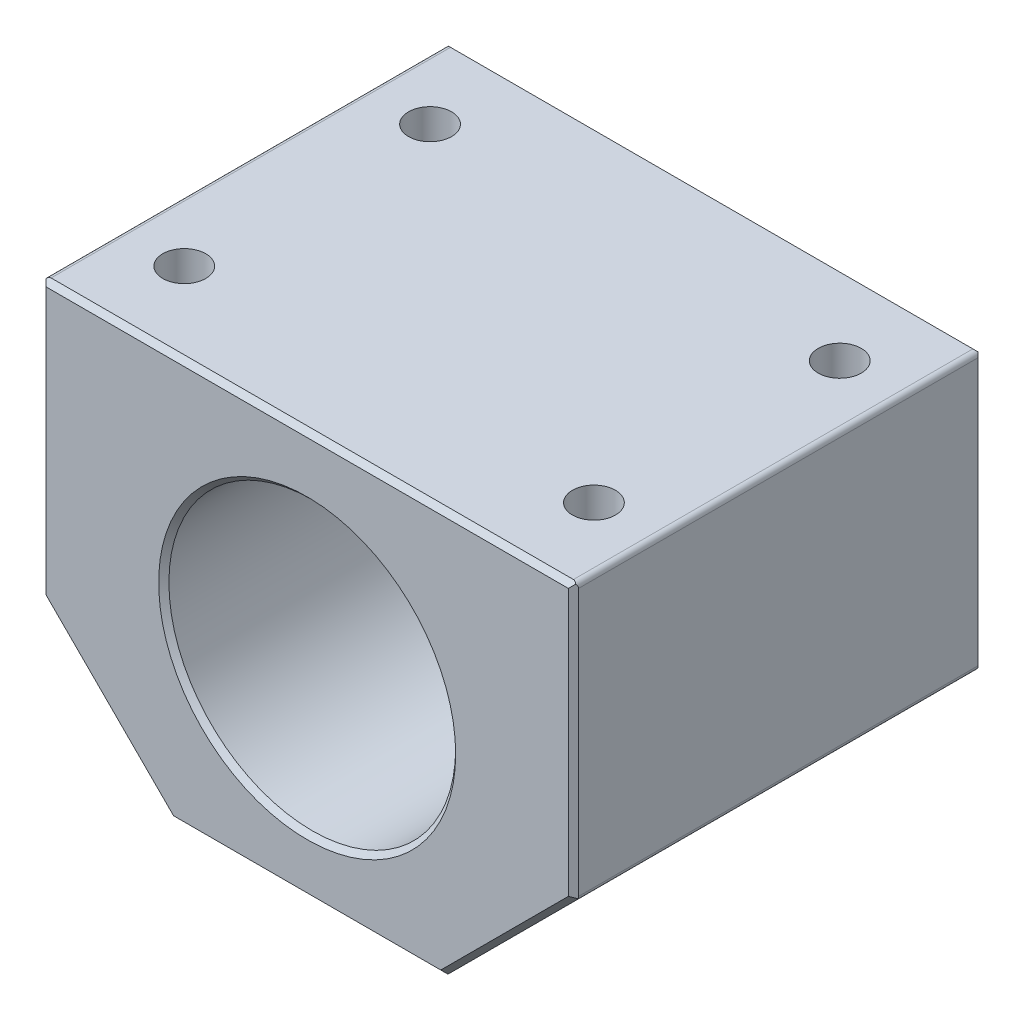
from build123d import *

# Parameters (mm, degrees)
SKETCH1_R                      = 14
BOSS_EXTRUDE1_DEPTH            = 20
CIRPATTERN1_COUNT              = 3
CIRPATTERN1_ANGLE              = 90
M5X0_8_TAPPED_HOLE2_AT_2_COUNT = 2
M5X0_8_TAPPED_HOLE2_AT_2_PITCH = 24
CHAMFER1_SIZE                  = 0.5
FILLET1_R                      = 0.5


with BuildPart() as part:
    # Sketch1 → Boss-Extrude1 (new body, symmetric)
    with BuildSketch(Plane.XY):
        Polygon((-13.25, -19.5), (13.25, -19.5), (26, -6.75), (26, 20), (-26, 20), (-26, -6.75), align=None)
        Circle(SKETCH1_R, mode=Mode.SUBTRACT)
    extrude(amount=BOSS_EXTRUDE1_DEPTH, both=True)

    # Sketch4 → M5x0.8 Tapped Hole1 (revolve, cut)
    with BuildSketch(Plane(origin=(13.435028843, 13.435028843, -20), x_dir=(0, 1, 0), z_dir=(1, 0, 0))):
        Polygon((0, 0), (0, 16.9218073), (2.1, 15.66), (2.1, 0), align=None)
    m5x0_8_tapped_hole1 = revolve(axis=Axis((13.435028843, 13.435028843, -26.35), (0, 0, 1)), mode=Mode.SUBTRACT)

    # CirPattern1: M5x0.8 Tapped Hole1 ×3 about axis
    cirpattern1_axis = Axis((0, 0, 0), (0, 0, -1))
    for i in range(1, CIRPATTERN1_COUNT):
        add(m5x0_8_tapped_hole1.rotate(cirpattern1_axis, i * CIRPATTERN1_ANGLE / (CIRPATTERN1_COUNT - 1)), mode=Mode.SUBTRACT)

    # Mirror1: M5x0.8 Tapped Hole1 across plane
    add(m5x0_8_tapped_hole1.mirror(Plane(origin=(0, 0, 0), x_dir=(0, 0, 1), z_dir=(1, 0, 0))), mode=Mode.SUBTRACT)

    # Mirror1 copy 1 sketch → Mirror1 copy 1 (revolve, cut)
    with BuildSketch(Plane(origin=(-19, 0, -20), x_dir=(-0.707106781, 0.707106781, 0), z_dir=(-0.707106781, -0.707106781, 0))):
        Polygon((0, 0), (0, -16.9218073), (2.1, -15.66), (2.1, 0), align=None)
    revolve(axis=Axis((-19, 0, -26.35), (0, 0, -1)), mode=Mode.SUBTRACT)

    # Mirror1 copy 2 sketch → Mirror1 copy 2 (revolve, cut)
    with BuildSketch(Plane(origin=(-13.435028843, -13.435028843, -20), x_dir=(-1, 0, 0), z_dir=(0, -1, 0))):
        Polygon((0, 0), (0, -16.9218073), (2.1, -15.66), (2.1, 0), align=None)
    revolve(axis=Axis((-13.435028843, -13.435028843, -26.35), (0, 0, -1)), mode=Mode.SUBTRACT)

    # Sketch6 → M5x0.8 Tapped Hole2 (revolve, cut)
    with BuildSketch(Plane(origin=(-20, 20, -12), x_dir=(0, 0, 1), z_dir=(1, 0, 0))):
        Polygon((0, 0), (0, 16.7618073), (2.1, 15.5), (2.1, 0), align=None)
    m5x0_8_tapped_hole2 = revolve(axis=Axis((-20, 26.35, -12), (0, -1, 0)), mode=Mode.SUBTRACT)

    # M5x0.8 Tapped Hole2 at 2: M5x0.8 Tapped Hole2 ×2
    with Locations(*[(0, 0, i * M5X0_8_TAPPED_HOLE2_AT_2_PITCH) for i in range(1, M5X0_8_TAPPED_HOLE2_AT_2_COUNT)]):
        add(m5x0_8_tapped_hole2, mode=Mode.SUBTRACT)

    # Mirror2: M5x0.8 Tapped Hole2 across plane
    add(m5x0_8_tapped_hole2.mirror(Plane(origin=(0, 0, 0), x_dir=(0, 0, 1), z_dir=(1, 0, 0))), mode=Mode.SUBTRACT)

    # Mirror2 copy 1 sketch → Mirror2 copy 1 (revolve, cut)
    with BuildSketch(Plane(origin=(20, 20, 12), x_dir=(0, 0, 1), z_dir=(-1, 0, 0))):
        Polygon((0, 0), (0, -16.7618073), (2.1, -15.5), (2.1, 0), align=None)
    revolve(axis=Axis((20, 26.35, 12), (0, 1, 0)), mode=Mode.SUBTRACT)

    # Chamfer1
    chamfer1_edges = [part.edges().sort_by_distance(p)[0] for p in [
        (0, 20, 20),
        (-26, 6.625, 20),
        (-14, 0, -20),
        (-14, 0, 20),
        (-19.625, -13.125, 20),
        (0, -19.5, 20),
        (19.625, -13.125, 20),
        (0, -19.5, -20),
        (-19.625, -13.125, -20),
        (-26, 6.625, -20),
        (0, 20, -20),
        (26, 6.625, -20),
        (19.625, -13.125, -20),
        (26, 6.625, 20),
    ]]
    chamfer(chamfer1_edges, length=CHAMFER1_SIZE)

    # Fillet1
    fillet1_edges = [part.edges().sort_by_distance(p)[0] for p in [
        (26, 20, 0),
        (26, -6.75, 0),
        (13.25, -19.5, 0),
        (-13.25, -19.5, 0),
        (-26, -6.75, 0),
        (-26, 20, 0),
    ]]
    fillet(fillet1_edges, radius=FILLET1_R)


solid = part.part
